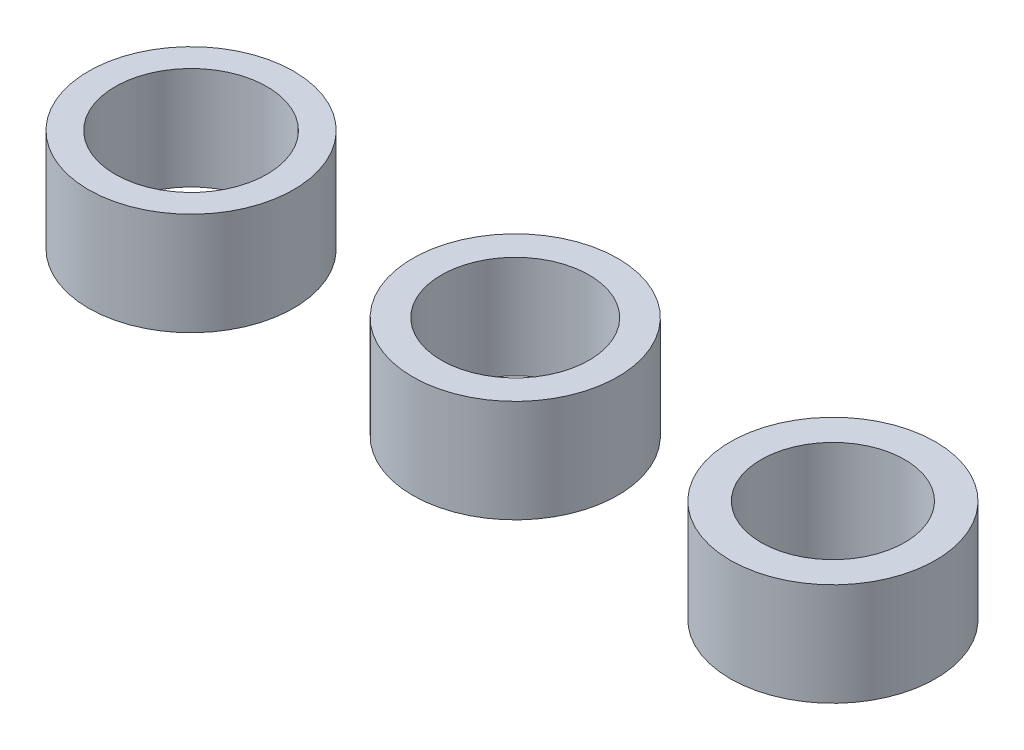
from build123d import *

# Parameters (mm, degrees)
SKETCH_1_R        = 5
SKETCH_1_R_2      = 3.7
EXTRUDE_1_DEPTH   = 5
SKETCH_1_R_3      = 3.6
EXTRUDE_1_2_DEPTH = 5
SKETCH_1_R_4      = 3.5
EXTRUDE_1_3_DEPTH = 5


with BuildPart() as part:
    # 草图1 → 凸台-拉伸1 (new body)
    with BuildSketch(Plane(origin=(0, 0, 0), x_dir=(1, 0, 0), z_dir=(0, 1, 0))):
        with Locations((5.437119386, 5.006908435)):
            Circle(SKETCH_1_R)
        with Locations((5.437119386, 5.006908435)):
            Circle(SKETCH_1_R_2, mode=Mode.SUBTRACT)
    extrude(amount=EXTRUDE_1_DEPTH)


with BuildPart() as body_2:
    # 草图1 → Extrude 1 2 (new body)
    with BuildSketch(Plane(origin=(0, 0, 0), x_dir=(1, 0, 0), z_dir=(0, 1, 0))):
        with Locations((21.230124471, 5.006908435)):
            Circle(SKETCH_1_R)
        with Locations((21.230124471, 5.006908435)):
            Circle(SKETCH_1_R_3, mode=Mode.SUBTRACT)
    extrude(amount=EXTRUDE_1_2_DEPTH)


with BuildPart() as body_3:
    # 草图1 → Extrude 1 3 (new body)
    with BuildSketch(Plane(origin=(0, 0, 0), x_dir=(1, 0, 0), z_dir=(0, 1, 0))):
        with Locations((36.708022169, 5.006908435)):
            Circle(SKETCH_1_R)
        with Locations((36.708022169, 5.006908435)):
            Circle(SKETCH_1_R_4, mode=Mode.SUBTRACT)
    extrude(amount=EXTRUDE_1_3_DEPTH)


solid = Compound([part.part, body_2.part, body_3.part])
